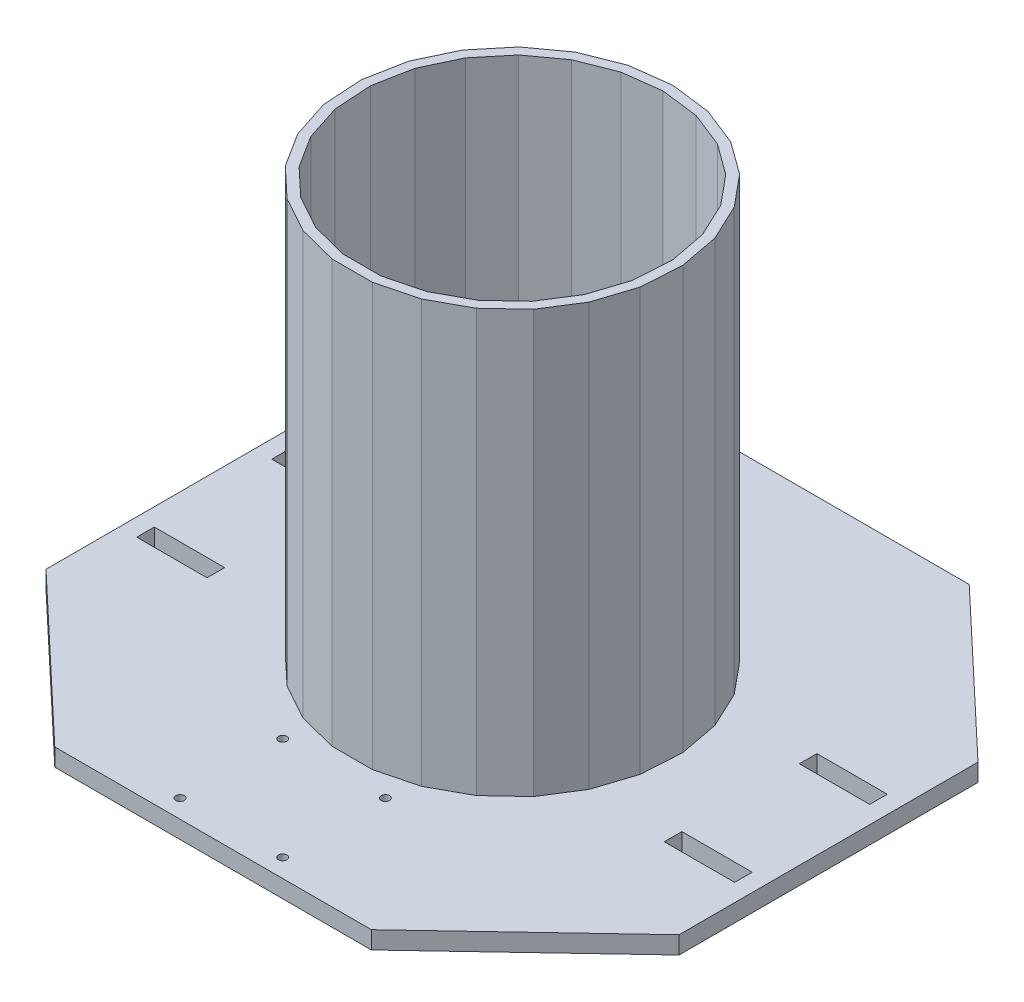
from build123d import *

# Parameters (mm, degrees)
SKETCH1_W           = 228.6
SKETCH1_H           = 215.9
BOSS_EXTRUDE1_DEPTH = 6.35
SKETCH8_W           = 25.4
SKETCH8_H           = 6.35
CUT_EXTRUDE2_DEPTH  = 7.35
SKETCH11_R          = 1.524
CUT_EXTRUDE4_DEPTH  = 7.35
CUT_EXTRUDE5_DEPTH  = 7.35
BOSS_EXTRUDE3_DEPTH = 152.4


with BuildPart() as part:
    # Sketch1 → Boss-Extrude1 (new body)
    with BuildSketch(Plane(origin=(0, 0, 0), x_dir=(1, 0, 0), z_dir=(0, 1, 0))):
        with Locations((114.3, 107.95)):
            Rectangle(SKETCH1_W, SKETCH1_H)
    extrude(amount=BOSS_EXTRUDE1_DEPTH)

    # Sketch8 → Cut-Extrude2 (cut, through all)
    with BuildSketch(Plane(origin=(0, 6.35, 0), x_dir=(1, 0, 0), z_dir=(0, 1, 0))):
        with Locations((19.05, 132.334)):
            Rectangle(SKETCH8_W, SKETCH8_H)
        with Locations((209.55, 132.334)):
            Rectangle(SKETCH8_W, SKETCH8_H)
        with Locations((209.55, 83.566)):
            Rectangle(SKETCH8_W, SKETCH8_H)
        with Locations((19.05, 83.566)):
            Rectangle(SKETCH8_W, SKETCH8_H)
    extrude(amount=-CUT_EXTRUDE2_DEPTH, mode=Mode.SUBTRACT)

    # Sketch11 → Cut-Extrude4 (cut, through all)
    with BuildSketch(Plane(origin=(0, 6.35, 0), x_dir=(1, 0, 0), z_dir=(0, 1, 0))):
        with Locations((95.758, 6.604)):
            Circle(SKETCH11_R)
        with Locations((132.842, 6.604)):
            Circle(SKETCH11_R)
        with Locations((132.842, 43.688)):
            Circle(SKETCH11_R)
        with Locations((95.758, 43.688)):
            Circle(SKETCH11_R)
    extrude(amount=-CUT_EXTRUDE4_DEPTH, mode=Mode.SUBTRACT)

    # Sketch13 → Cut-Extrude5 (cut, through all)
    with BuildSketch(Plane(origin=(0, 6.35, 0), x_dir=(1, 0, 0), z_dir=(0, 1, 0))):
        Polygon((0, 215.9), (0, 161.925), (57.15, 215.9), align=None)
        Polygon((228.6, 161.925), (171.45, 215.9), (228.6, 215.9), align=None)
        Polygon((228.6, 0), (228.6, 53.975), (171.45, 0), align=None)
        Polygon((0, 53.975), (57.15, 0), (0, 0), align=None)
    extrude(amount=-CUT_EXTRUDE5_DEPTH, mode=Mode.SUBTRACT)

    # Sketch18 → Boss-Extrude3 (add)
    with BuildSketch(Plane(origin=(0, 6.35, 0), x_dir=(1, 0, 0), z_dir=(0, 1, 0))):
        Polygon((114.3, 166.095906935), (99.839700965, 164.269146346), (86.2879957, 158.903646664), (74.496387686, 150.336541968), (65.205787021, 139.106134954), (58.999956314, 125.918073396), (56.26883073, 111.601011705), (57.184016936, 97.054543521), (61.688010415, 83.192676938), (69.497808694, 70.886404014), (80.122693423, 60.908973136), (92.895064019, 53.887302981), (107.012385465, 50.262590909), (121.587614535, 50.262590909), (135.704935981, 53.887302981), (148.477306577, 60.908973136), (159.102191306, 70.886404014), (166.911989585, 83.192676938), (171.415983064, 97.054543521), (172.33116927, 111.601011705), (169.600043686, 125.918073396), (163.394212979, 139.106134954), (154.103612314, 150.336541968), (142.3120043, 158.903646664), (128.760299035, 164.269146346), align=None)
        Polygon((114.3, 162.56), (100.719045262, 160.844326429), (87.991431857, 155.805107797), (76.916882545, 147.758976743), (68.191251988, 137.211501274), (62.362803645, 124.825418063), (59.797760361, 111.378990271), (60.657293238, 97.71710641), (64.887394665, 84.698192888), (72.222271812, 73.14027592), (82.201047372, 63.769581937), (94.196718178, 57.174906106), (107.455552115, 53.770616161), (121.144447885, 53.770616161), (134.403281822, 57.174906106), (146.398952628, 63.769581937), (156.377728188, 73.14027592), (163.712605335, 84.698192888), (167.942706762, 97.71710641), (168.802239639, 111.378990271), (166.237196355, 124.825418063), (160.408748012, 137.211501274), (151.683117455, 147.758976743), (140.608568143, 155.805107797), (127.880954738, 160.844326429), align=None, mode=Mode.SUBTRACT)
    extrude(amount=BOSS_EXTRUDE3_DEPTH)


solid = part.part
